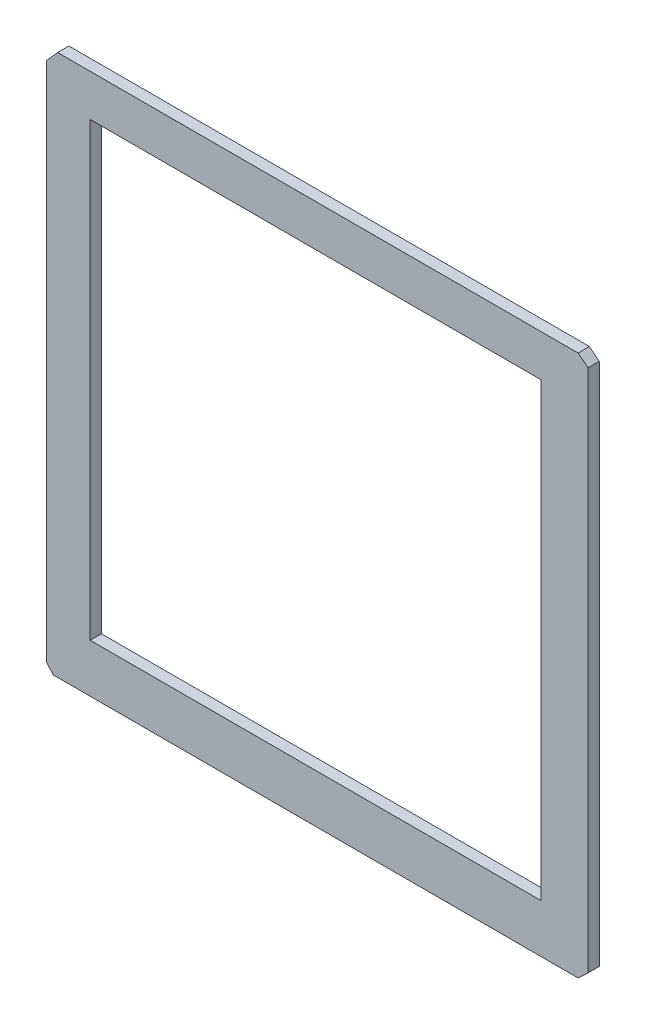
from build123d import *

# Parameters (mm, degrees)
CROQUIS1_W              = 40
CROQUIS1_H              = 40
SALIENTE_EXTRUIR1_DEPTH = 1


with BuildPart() as part:
    # Croquis1 → Saliente-Extruir1 (new body)
    with BuildSketch(Plane.XY):
        Polygon((-55.179144712, 38.106772101), (-9.021007114, 38.106772101), (-8.146009312, 37.404287676), (-8.146009312, -9.068040036), (-9.021007114, -9.893227899), (-55.574998645, -9.893227899), (-56.146009312, -9.223291846), (-56.146009312, 37.023243982), align=None)
        with Locations((-32.293778979, 14.407420925)):
            Rectangle(CROQUIS1_W, CROQUIS1_H, mode=Mode.SUBTRACT)
    extrude(amount=SALIENTE_EXTRUIR1_DEPTH)


solid = part.part
